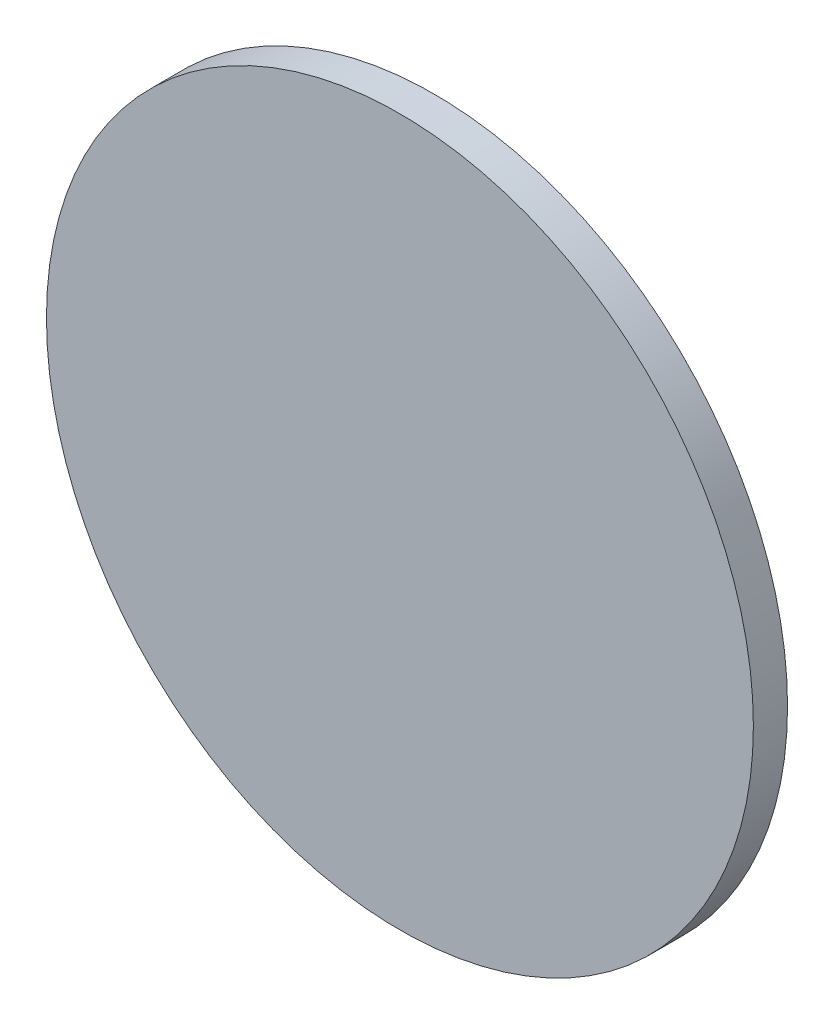
from build123d import *

# Parameters (mm, degrees)
SKETCH1_R           = 16.4211
BOSS_EXTRUDE1_DEPTH = 1.5875


with BuildPart() as part:
    # Sketch1 → Boss-Extrude1 (new body)
    with BuildSketch(Plane.XY):
        Circle(SKETCH1_R)
    extrude(amount=BOSS_EXTRUDE1_DEPTH)


solid = part.part
